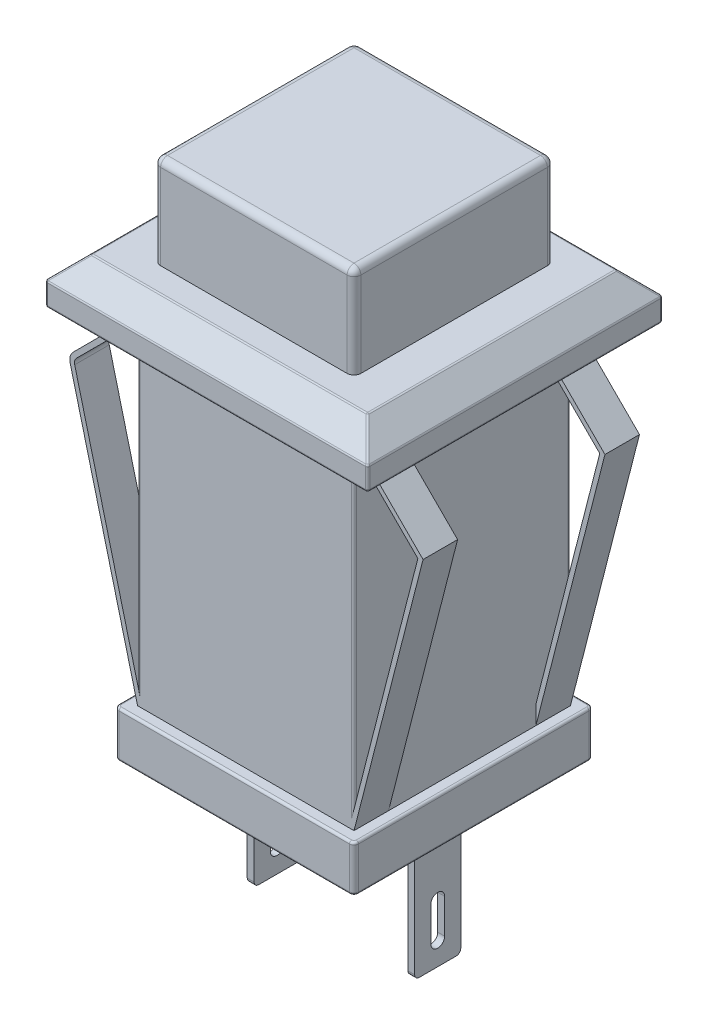
from build123d import *

# Parameters (mm, degrees)
BOSS_EXTRUDE1_DEPTH   = 4
SKETCH2_W             = 14
SKETCH2_H             = 12.81782418
BOSS_EXTRUDE3_DEPTH   = 2
CHAMFER1_SIZE         = 1
FILLET1_R             = 0.3
SKETCH3_W             = 10.4
SKETCH3_H             = 10.4
BOSS_EXTRUDE4_DEPTH   = 16.7
CUT_EXTRUDE2_START    = -2
SKETCH4_W             = 10.4
SKETCH4_H             = 10.4
SKETCH4_W_2           = 9.4
SKETCH4_H_2           = 9.4
CUT_EXTRUDE2_DEPTH    = 14.7
BOSS_EXTRUDE5_DEPTH   = 1.5
BOSS_EXTRUDE5_2_DEPTH = 1.5
FILLET2_R             = 0.3
FILLET3_R             = 0.5
FILLET2_OF_MIRROR3_R  = 0.3
FILLET3_OF_MIRROR3_R  = 0.5
SKETCH7_W             = 0.3
SKETCH7_H             = 2
BOSS_EXTRUDE6_DEPTH   = 6
CUT_EXTRUDE3_DEPTH    = 7.987119
FILLET4_R             = 0.2
SKETCH9_R             = 0.5
CUT_EXTRUDE4_DEPTH    = 10
FILLET5_R             = 0.1
FILLET6_R             = 0.1


with BuildPart() as part:
    # Sketch1 → Boss-Extrude1 (new body)
    with BuildSketch(Plane(origin=(0, 0, 0), x_dir=(1, 0, 0), z_dir=(0, 1, 0))):
        with BuildLine():
            Line((-4.05, 4.35), (4.05, 4.35))
            ThreePointArc((4.05, 4.35), (4.262132034, 4.262132034), (4.35, 4.05))
            Line((4.35, 4.05), (4.35, -4.05))
            ThreePointArc((4.35, -4.05), (4.262132034, -4.262132034), (4.05, -4.35))
            Line((4.05, -4.35), (-4.05, -4.35))
            ThreePointArc((-4.05, -4.35), (-4.262132034, -4.262132034), (-4.35, -4.05))
            Line((-4.35, -4.05), (-4.35, 4.05))
            ThreePointArc((-4.35, 4.05), (-4.262132034, 4.262132034), (-4.05, 4.35))
        make_face()
    extrude(amount=BOSS_EXTRUDE1_DEPTH)

    # Fillet1
    fillet1_edges = [part.edges().sort_by_distance(p)[0] for p in [
        (4.262132034, 4, 4.262132034),
        (4.35, 4, 0),
        (4.262132034, 4, -4.262132034),
        (0, 4, -4.35),
        (-4.262132034, 4, -4.262132034),
        (-4.35, 4, 0),
        (-4.262132034, 4, 4.262132034),
        (0, 4, 4.35),
    ]]
    fillet(fillet1_edges, radius=FILLET1_R)


with BuildPart() as body_2:
    # Sketch2 → Boss-Extrude3 (new body)
    with BuildSketch(Plane.XZ):
        Rectangle(SKETCH2_W, SKETCH2_H)
    extrude(amount=BOSS_EXTRUDE3_DEPTH)

    # Chamfer1
    chamfer1_edges = [body_2.edges().sort_by_distance(p)[0] for p in [
        (0, 0, -6.40891209),
        (-7, 0, 0),
        (0, 0, 6.40891209),
        (7, 0, 0),
    ]]
    chamfer(chamfer1_edges, length=CHAMFER1_SIZE)

    # Fillet6
    fillet6_edges = [body_2.edges().sort_by_distance(p)[0] for p in [
        (-7, -2, 0),
        (0, -2, -6.40891209),
        (7, -1, 0),
        (-6, 0, 0),
        (0, 0, -5.40891209),
        (0, 0, 5.40891209),
        (6, 0, 0),
        (0, -1, 6.40891209),
        (0, -1, -6.40891209),
        (-7, -1, 0),
        (-6.5, -0.5, -5.90891209),
        (-6.5, -0.5, 5.90891209),
        (6.5, -0.5, -5.90891209),
        (6.5, -0.5, 5.90891209),
        (7, -2, 0),
        (0, -2, 6.40891209),
        (7, -1.5, -6.40891209),
        (-7, -1.5, -6.40891209),
        (-7, -1.5, 6.40891209),
        (7, -1.5, 6.40891209),
    ]]
    fillet(fillet6_edges, radius=FILLET6_R)


with BuildPart() as body_3:
    # Sketch3 → Boss-Extrude4 (new body)
    with BuildSketch(Plane.XZ.offset(2)):
        Rectangle(SKETCH3_W, SKETCH3_H)
    extrude(amount=BOSS_EXTRUDE4_DEPTH)

    # Sketch4 → Cut-Extrude2 (cut)
    with BuildSketch(Plane.XZ.offset(18.7).offset(CUT_EXTRUDE2_START)):
        Rectangle(SKETCH4_W, SKETCH4_H)
        Rectangle(SKETCH4_W_2, SKETCH4_H_2, mode=Mode.SUBTRACT)
    extrude(amount=-CUT_EXTRUDE2_DEPTH, mode=Mode.SUBTRACT)


with BuildPart() as body_4:
    # Sketch6 → Boss-Extrude5 (new body)
    with BuildSketch(Plane(origin=(0, 0, -4.7), x_dir=(-1, 0, 0), z_dir=(0, 0, -1))):
        Polygon((4.7, -16.7), (7.7, -5), (4.7, -2), (4.7, -2.3), (7.474442268, -5.074442268), (4.7, -15.894767114), align=None)
    boss_extrude5 = extrude(amount=-BOSS_EXTRUDE5_DEPTH)

    # Fillet2
    fillet2_edges = [body_4.edges().sort_by_distance(p)[0] for p in [
        (-7.474442268, -5.074442268, -3.95),
    ]]
    fillet(fillet2_edges, radius=FILLET2_R)

    # Fillet3
    fillet3_edges = [body_4.edges().sort_by_distance(p)[0] for p in [
        (-7.7, -5, -3.95),
    ]]
    fillet(fillet3_edges, radius=FILLET3_R)


with BuildPart() as body_5:
    # Sketch6 → Boss-Extrude5 2 (new body)
    with BuildSketch(Plane(origin=(0, 0, -4.7), x_dir=(-1, 0, 0), z_dir=(0, 0, -1))):
        Polygon((-4.7, -15.894767114), (-4.7, -16.7), (-7.7, -5), (-4.7, -2), (-4.7, -2.3), (-7.474442268, -5.074442268), align=None)
    boss_extrude5_2 = extrude(amount=-BOSS_EXTRUDE5_2_DEPTH)


with BuildPart() as body_3_1:
    add(body_3.part)

    # Mirror3: Boss-Extrude5, Boss-Extrude5 2 across plane
    add(boss_extrude5.mirror(Plane.XY))
    add(boss_extrude5_2.mirror(Plane.XY))

    # Fillet2 of Mirror3
    fillet2_of_mirror3_edges = [body_3_1.edges().sort_by_distance(p)[0] for p in [
        (-7.474442268, -5.074442268, 3.95),
    ]]
    fillet(fillet2_of_mirror3_edges, radius=FILLET2_OF_MIRROR3_R)

    # Fillet3 of Mirror3
    fillet3_of_mirror3_edges = [body_3_1.edges().sort_by_distance(p)[0] for p in [
        (-7.7, -5, 3.95),
    ]]
    fillet(fillet3_of_mirror3_edges, radius=FILLET3_OF_MIRROR3_R)

    # Sketch7 → Boss-Extrude6 (add)
    with BuildSketch(Plane.XZ.offset(18.7)):
        with Locations((-3.487119208, 0)):
            Rectangle(SKETCH7_W, SKETCH7_H)
        with Locations((3.487119208, 0)):
            Rectangle(SKETCH7_W, SKETCH7_H)
    extrude(amount=BOSS_EXTRUDE6_DEPTH)

    # Sketch8 → Cut-Extrude3 (cut)
    with BuildSketch(Plane.ZY.offset(3.637119208)):
        with BuildLine():
            Line((0.3, -22.2), (0.3, -23.7))
            ThreePointArc((0.3, -23.7), (0, -24), (-0.3, -23.7))
            Line((-0.3, -23.7), (-0.3, -22.2))
            ThreePointArc((-0.3, -22.2), (0, -21.9), (0.3, -22.2))
        make_face()
    extrude(amount=-CUT_EXTRUDE3_DEPTH, mode=Mode.SUBTRACT)

    # Fillet4
    fillet4_edges = [body_3_1.edges().sort_by_distance(p)[0] for p in [
        (5.2, -17.7, -5.2),
        (-5.2, -17.7, -5.2),
        (-5.2, -17.7, 5.2),
        (5.2, -17.7, 5.2),
        (-3.487119208, -24.7, -1),
        (-3.487119208, -24.7, 1),
        (3.487119208, -24.7, 1),
        (3.487119208, -24.7, -1),
    ]]
    fillet(fillet4_edges, radius=FILLET4_R)

    # Sketch9 → Cut-Extrude4 (cut)
    with BuildSketch(Plane.XZ.offset(18.7)):
        Circle(SKETCH9_R)
    extrude(amount=-CUT_EXTRUDE4_DEPTH, mode=Mode.SUBTRACT)

    # Fillet5
    fillet5_edges = [body_3_1.edges().sort_by_distance(p)[0] for p in [
        (0, -16.7, -5.2),
        (0, -18.7, -5.2),
        (-5.2, -16.7, 0),
        (0, -16.7, 5.2),
        (5.2, -16.7, 0),
        (-5.141421356, -16.7, 5.141421356),
        (5.141421356, -16.7, 5.141421356),
        (5.141421356, -16.7, -5.141421356),
        (-5.141421356, -16.7, -5.141421356),
        (-5.2, -18.7, 0),
        (5.2, -18.7, 0),
        (0, -18.7, 5.2),
        (-5.141421356, -18.7, 5.141421356),
        (5.141421356, -18.7, 5.141421356),
        (5.141421356, -18.7, -5.141421356),
        (-5.141421356, -18.7, -5.141421356),
        (-4.7, -9.35, -4.7),
        (4.7, -9.35, -4.7),
        (-4.7, -9.097383557, 4.7),
        (4.7, -9.097383557, 4.7),
    ]]
    fillet(fillet5_edges, radius=FILLET5_R)


solid = Compound([part.part, body_2.part, body_4.part, body_5.part, body_3_1.part])
